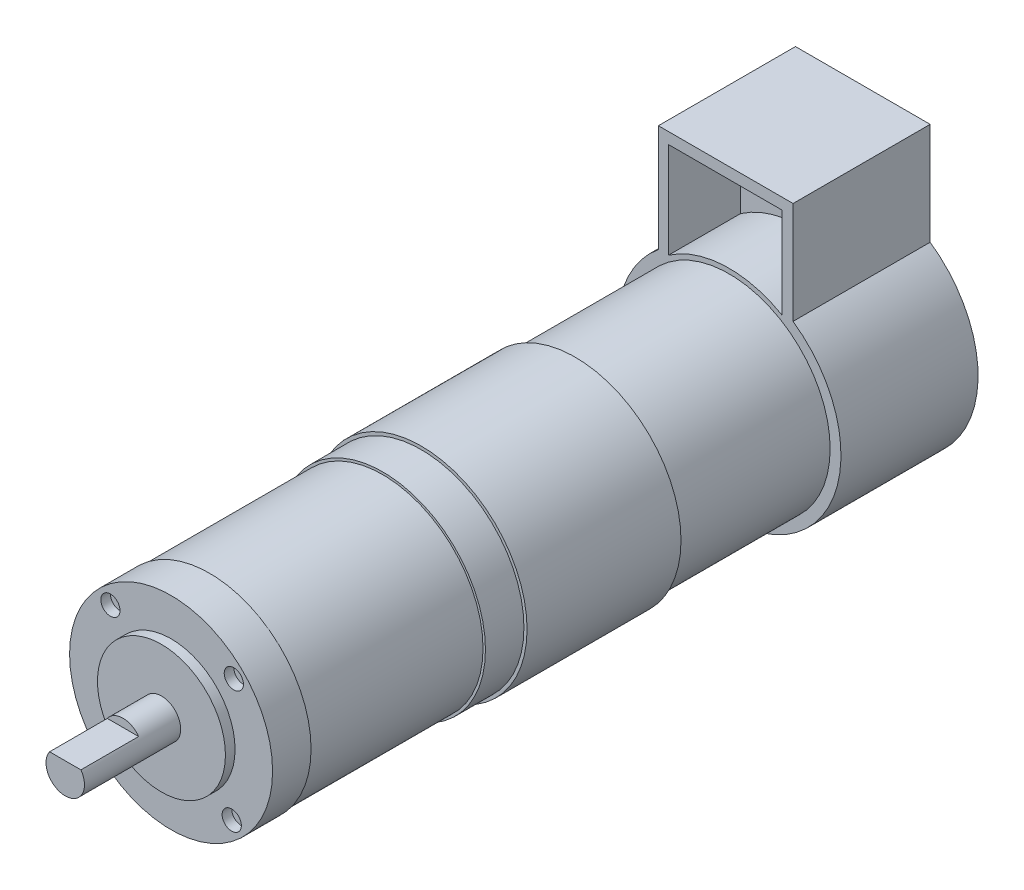
from build123d import *

# Parameters (mm, degrees)
BOSS_EXTRUDE1_DEPTH          = 28.5
SKETCH2_R                    = 21
BOSS_EXTRUDE2_DEPTH          = 32
SKETCH3_R                    = 22
BOSS_EXTRUDE3_DEPTH          = 32
SKETCH4_R                    = 21.35
BOSS_EXTRUDE4_DEPTH          = 8
SKETCH5_R                    = 20.85
BOSS_EXTRUDE5_DEPTH          = 36
SKETCH6_W                    = 28
SKETCH6_H                    = 28.5
BOSS_EXTRUDE6_DEPTH          = 21.22463282
SKETCH7_R                    = 21.1
BOSS_EXTRUDE7_DEPTH          = 8
SKETCH8_R                    = 13.3
BOSS_EXTRUDE8_DEPTH          = 2
SKETCH9_R                    = 4
BOSS_EXTRUDE9_DEPTH          = 20
CUT_EXTRUDE1_DEPTH           = 12
CUT_EXTRUDE2_DEPTH           = 15
F_4_0_4_DIAMETER_HOLE1_D     = 4
F_4_0_4_DIAMETER_HOLE1_DEPTH = 2


with BuildPart() as part:
    # Sketch1 → Boss-Extrude1 (new body)
    with BuildSketch(Plane(origin=(0, 0, 0), x_dir=(-1, 0, 0), z_dir=(0, 0, -1))):
        with BuildLine():
            Line((14.707413083, 18.007068068), (14.707413083, 19.07536718))
            Line((14.707413083, 19.07536718), (-13.292586917, 19.07536718))
            ThreePointArc((-13.292586917, 19.07536718), (-0.886424853, -23.233096027), (14.707413083, 18.007068068))
        make_face()
    extrude(amount=-BOSS_EXTRUDE1_DEPTH)

    # Sketch2 → Boss-Extrude2 (add)
    with BuildSketch(Plane.XY.offset(28.5)):
        Circle(SKETCH2_R)
    extrude(amount=BOSS_EXTRUDE2_DEPTH)

    # Sketch3 → Boss-Extrude3 (add)
    with BuildSketch(Plane(origin=(0, 0, 60.5), x_dir=(-1, 0, 0), z_dir=(0, 0, -1))):
        Circle(SKETCH3_R)
    extrude(amount=-BOSS_EXTRUDE3_DEPTH)

    # Sketch4 → Boss-Extrude4 (add)
    with BuildSketch(Plane.XY.offset(92.5)):
        Circle(SKETCH4_R)
    extrude(amount=BOSS_EXTRUDE4_DEPTH)

    # Sketch5 → Boss-Extrude5 (add)
    with BuildSketch(Plane.XY.offset(100.5)):
        Circle(SKETCH5_R)
    extrude(amount=BOSS_EXTRUDE5_DEPTH)

    # Sketch6 → Boss-Extrude6 (add)
    with BuildSketch(Plane(origin=(0, 19.07536718, 0), x_dir=(-1, 0, 0), z_dir=(0, 1, 0))):
        with Locations((0.707413083, 14.25)):
            Rectangle(SKETCH6_W, SKETCH6_H)
    extrude(amount=BOSS_EXTRUDE6_DEPTH)

    # Sketch7 → Boss-Extrude7 (add)
    with BuildSketch(Plane(origin=(0, 0, 136.5), x_dir=(-1, 0, 0), z_dir=(0, 0, -1))):
        Circle(SKETCH7_R)
    extrude(amount=-BOSS_EXTRUDE7_DEPTH)

    # Sketch8 → Boss-Extrude8 (add)
    with BuildSketch(Plane.XY.offset(144.5)):
        Circle(SKETCH8_R)
    extrude(amount=BOSS_EXTRUDE8_DEPTH)

    # Sketch9 → Boss-Extrude9 (add)
    with BuildSketch(Plane.XY.offset(146.5)):
        Circle(SKETCH9_R)
    extrude(amount=BOSS_EXTRUDE9_DEPTH)

    # Sketch10 → Cut-Extrude1 (cut)
    with BuildSketch(Plane.XY.offset(166.5)):
        with BuildLine():
            Line((-3.255366619, 2.324346828), (3.255366619, 2.324346828))
            ThreePointArc((3.255366619, 2.324346828), (0, 4), (-3.255366619, 2.324346828))
        make_face()
    extrude(amount=-CUT_EXTRUDE1_DEPTH, mode=Mode.SUBTRACT)

    # Sketch11 → Cut-Extrude2 (cut)
    with BuildSketch(Plane.XY.offset(28.5)):
        with BuildLine():
            Line((10.960399944, 19.07536718), (10.960399944, 37.965647442))
            Line((10.960399944, 37.965647442), (-12.639046626, 37.965647442))
            Line((-12.639046626, 37.965647442), (-12.639046626, 18.007068068))
            ThreePointArc((-12.639046626, 18.007068068), (-0.994876585, 21.977493501), (10.960399944, 19.07536718))
        make_face()
    extrude(amount=-CUT_EXTRUDE2_DEPTH, mode=Mode.SUBTRACT)

    # Ø4.0 (4) Diameter Hole1
    with Locations(Plane.XY.offset(144.5)):
        with Locations((-13.043990964, -12.610936722), (12.610936722, -13.043990964), (13.043990964, 12.610936722), (-12.610936722, 13.043990964)):
            Hole(F_4_0_4_DIAMETER_HOLE1_D / 2, depth=F_4_0_4_DIAMETER_HOLE1_DEPTH)


solid = part.part
